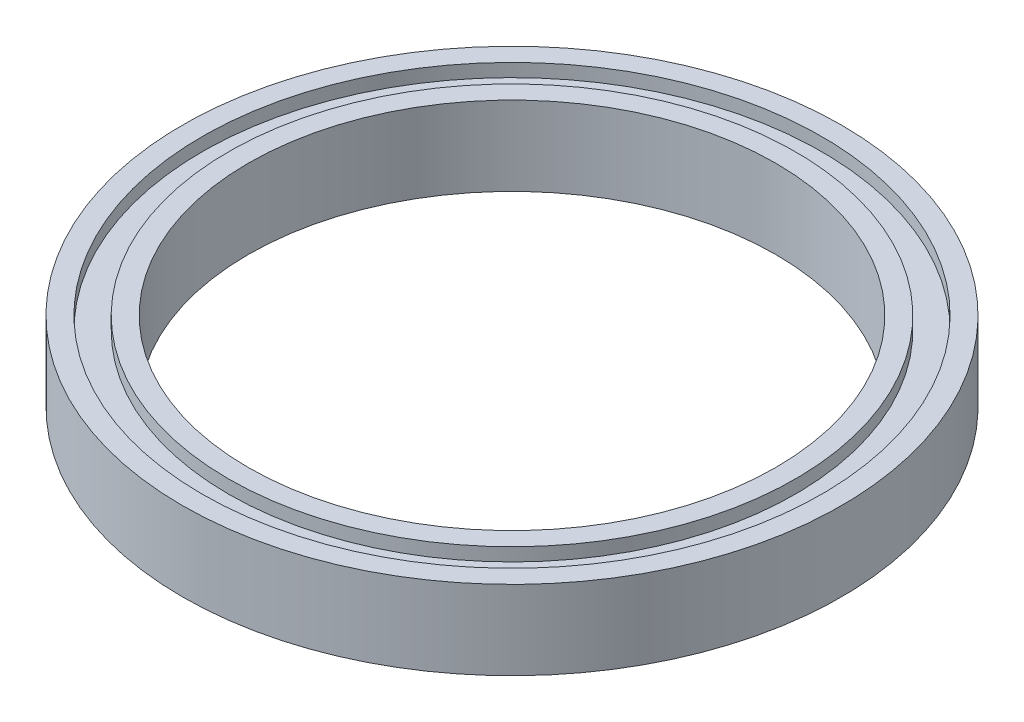
from build123d import *

# Parameters (mm, degrees)
SKETCH1_R           = 25
SKETCH1_R_2         = 20
BOSS_EXTRUDE1_DEPTH = 6
SKETCH2_R           = 23.5
SKETCH2_R_2         = 21.5
CUT_EXTRUDE1_DEPTH  = 1
SKETCH3_R           = 23
SKETCH3_R_2         = 22
CUT_EXTRUDE2_DEPTH  = 1


with BuildPart() as part:
    # Sketch1 → Boss-Extrude1 (new body)
    with BuildSketch(Plane(origin=(0, 0, 0), x_dir=(1, 0, 0), z_dir=(0, 1, 0))):
        Circle(SKETCH1_R)
        Circle(SKETCH1_R_2, mode=Mode.SUBTRACT)
    extrude(amount=BOSS_EXTRUDE1_DEPTH)

    # Sketch2 → Cut-Extrude1 (cut)
    with BuildSketch(Plane(origin=(0, 6, 0), x_dir=(1, 0, 0), z_dir=(0, 1, 0))):
        Circle(SKETCH2_R)
        Circle(SKETCH2_R_2, mode=Mode.SUBTRACT)
    extrude(amount=-CUT_EXTRUDE1_DEPTH, mode=Mode.SUBTRACT)

    # Sketch3 → Cut-Extrude2 (cut)
    with BuildSketch(Plane.XZ):
        Circle(SKETCH3_R)
        Circle(SKETCH3_R_2, mode=Mode.SUBTRACT)
    extrude(amount=-CUT_EXTRUDE2_DEPTH, mode=Mode.SUBTRACT)


solid = part.part
